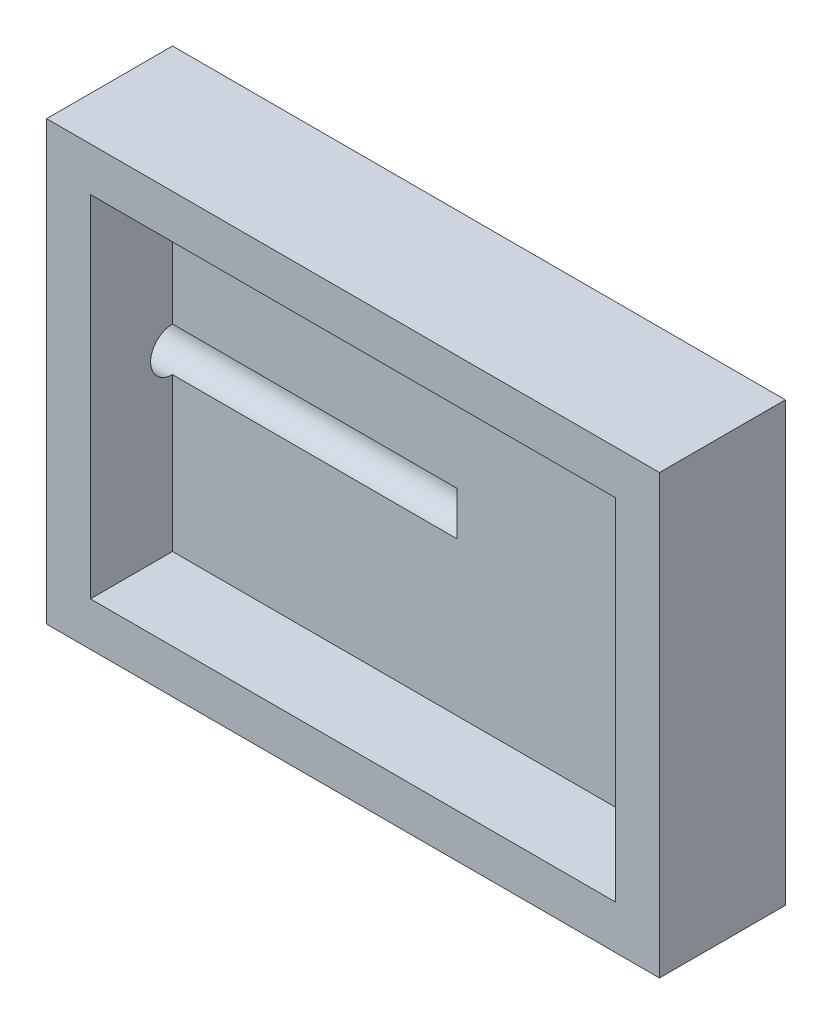
from build123d import *

# Parameters (mm, degrees)
SKETCH1_W           = 355.6
SKETCH1_H           = 254
BOSS_EXTRUDE1_DEPTH = 36.5125
SHELL1_T            = -25.4
SKETCH2_R           = 12.7
CUT_EXTRUDE1_DEPTH  = 190.5


with BuildPart() as part:
    # Sketch1 → Boss-Extrude1 (new body, symmetric)
    with BuildSketch(Plane.XY):
        Rectangle(SKETCH1_W, SKETCH1_H)
    extrude(amount=BOSS_EXTRUDE1_DEPTH, both=True)

    # Shell1
    shell1_openings = [part.faces().sort_by_distance(p)[0] for p in [
        (0, 0, 36.5125),
    ]]
    offset(amount=SHELL1_T, openings=shell1_openings, kind=Kind.INTERSECTION)

    # Sketch2 → Cut-Extrude1 (cut)
    with BuildSketch(Plane.ZY.offset(177.8)):
        with Locations((-11.1125, 0)):
            Circle(SKETCH2_R)
    extrude(amount=-CUT_EXTRUDE1_DEPTH, mode=Mode.SUBTRACT)


solid = part.part
